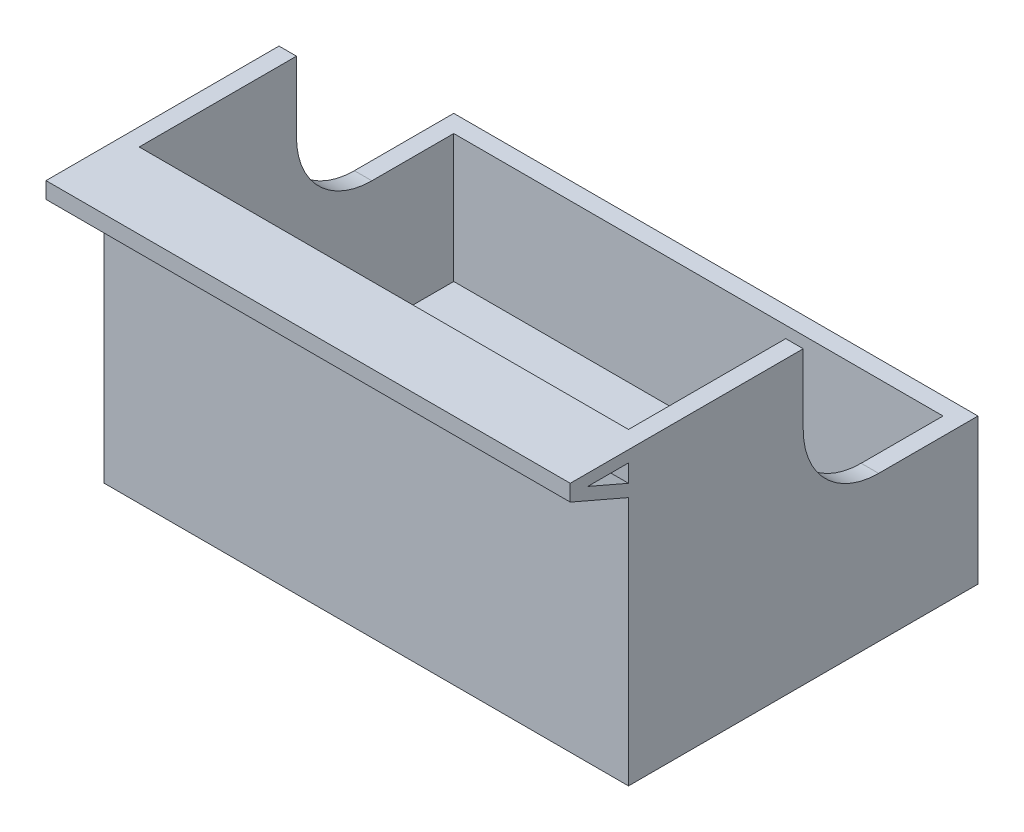
from build123d import *

# Parameters (mm, degrees)
SKETCH1_W           = 90
SKETCH1_H           = 60
BOSS_EXTRUDE1_DEPTH = 50
SHELL1_T            = -3
CUT_EXTRUDE1_DEPTH  = 90
BOSS_EXTRUDE2_DEPTH = 90


with BuildPart() as part:
    # Sketch1 → Boss-Extrude1 (new body)
    with BuildSketch(Plane(origin=(0, 0, 0), x_dir=(1, 0, 0), z_dir=(0, 1, 0))):
        Rectangle(SKETCH1_W, SKETCH1_H)
    extrude(amount=BOSS_EXTRUDE1_DEPTH)

    # Shell1
    shell1_openings = [part.faces().sort_by_distance(p)[0] for p in [
        (0, 50, 0),
    ]]
    offset(amount=SHELL1_T, openings=shell1_openings, kind=Kind.INTERSECTION)

    # Sketch2 → Cut-Extrude1 (cut)
    with BuildSketch(Plane.ZY.offset(45)):
        with BuildLine():
            Line((-30, 25), (-12.94347358, 25))
            ThreePointArc((-12.94347358, 25), (-3.791055639, 28.791055639), (0, 37.94347358))
            Line((0, 37.94347358), (0, 50))
            Line((0, 50), (-30, 50))
            Line((-30, 50), (-30, 25))
        make_face()
    extrude(amount=-CUT_EXTRUDE1_DEPTH, mode=Mode.SUBTRACT)

    # Sketch3 → Boss-Extrude2 (add)
    with BuildSketch(Plane.ZY.offset(45)):
        Polygon((30, 50), (40, 50), (40, 47.197660371), (30, 42.867982808), (30, 44.997500312), (37, 48.028274606), (30, 48.028274606), align=None)
    extrude(amount=-BOSS_EXTRUDE2_DEPTH)


solid = part.part
